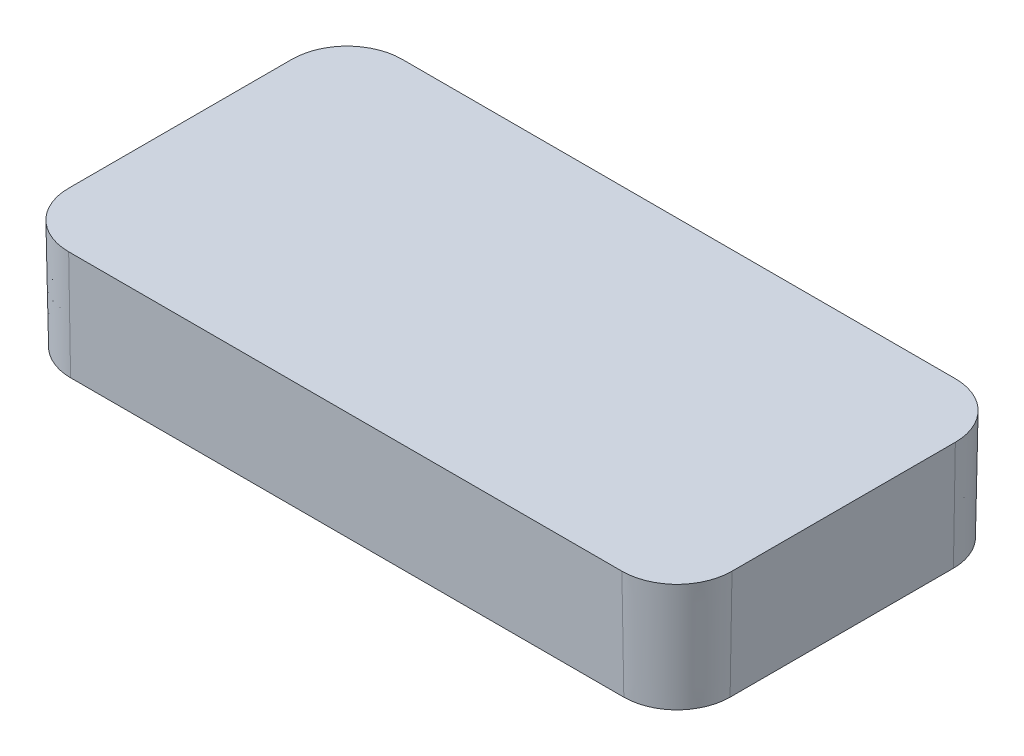
from build123d import *

# Parameters (mm, degrees)
BOSS_EXTRUDE1_DEPTH             = 2.3622
BOSS_EXTRUDE1_DRAFT             = -1
BOSS_EXTRUDE3_DEPTH             = 6.35
BOSS_EXTRUDE3_DRAFT             = -1
DRAFT1_ANGLE                    = 10
BOSS_EXTRUDE4_REACH             = 24.328
BOSS_EXTRUDE4_DIRECTION_2_REACH = 24.328
LPATTERN1_COUNT                 = 12
LPATTERN1_PITCH                 = 1.5875
LPATTERN1_COL_COUNT             = 12
LPATTERN1_COL_PITCH             = 1.5875
BOSS_EXTRUDE5_DEPTH             = 17.78
LPATTERN2_COUNT                 = 6
LPATTERN2_PITCH                 = 1.5875
LPATTERN2_COL_COUNT             = 6
LPATTERN2_COL_PITCH             = 1.5875
BOSS_EXTRUDE6_REACH             = 24.124
SKETCH10_R                      = 1.1811
SKETCH11_R                      = 1.1811
CUT_EXTRUDE1_DEPTH              = 23.123841069
MIRROR2_COPY_1_REACH            = 24.124
MIRROR2_COPY_1_SKETCH_R         = 1.1811
MIRROR2_COPY_2_SKETCH_R         = 1.1811
MIRROR2_COPY_2_DEPTH            = 23.123841069


with BuildPart() as part:
    # Sketch1 → Boss-Extrude1 (with draft: the straight prism first)
    with BuildSketch(Plane(origin=(0, 0, 0), x_dir=(1, 0, 0), z_dir=(0, 1, 0))):
        with BuildLine():
            Line((-15.9512, -9.6139), (15.9512, -9.6139))
            ThreePointArc((15.9512, -9.6139), (18.19626403, -8.68396403), (19.1262, -6.4389))
            Line((19.1262, -6.4389), (19.1262, 6.4389))
            ThreePointArc((19.1262, 6.4389), (18.19626403, 8.68396403), (15.9512, 9.6139))
            Line((15.9512, 9.6139), (-15.9512, 9.6139))
            ThreePointArc((-15.9512, 9.6139), (-18.19626403, 8.68396403), (-19.1262, 6.4389))
            Line((-19.1262, 6.4389), (-19.1262, -6.4389))
            ThreePointArc((-19.1262, -6.4389), (-18.19626403, -8.68396403), (-15.9512, -9.6139))
        make_face()
    extrude(amount=-BOSS_EXTRUDE1_DEPTH)
    # Boss-Extrude1: the draft: its side faces are tilted about the plane it starts from
    boss_extrude1_sides = [part.faces().sort_by_distance(p)[0] for p in [
        (0, -1.1811, 9.6139),
        (18.19626403, -1.1811, 8.68396403),
        (19.1262, -1.1811, 0),
        (18.19626403, -1.1811, -8.68396403),
        (0, -1.1811, -9.6139),
        (-18.19626403, -1.1811, -8.68396403),
        (-19.1262, -1.1811, 0),
        (-18.19626403, -1.1811, 8.68396403),
    ]]
    draft(boss_extrude1_sides, Plane(origin=(0, 0, 0), x_dir=(1, 0, 0), z_dir=(0, 1, 0)), BOSS_EXTRUDE1_DRAFT)


with BuildPart() as boss_extrude3_tool:
    # Sketch7 → Boss-Extrude3 (with draft: the straight prism first)
    with BuildSketch(Plane(origin=(0, 0, 0), x_dir=(1, 0, 0), z_dir=(0, 1, 0))):
        with BuildLine():
            Line((-15.9512, -9.6139), (15.9512, -9.6139))
            ThreePointArc((15.9512, -9.6139), (18.19626403, -8.68396403), (19.1262, -6.4389))
            Line((19.1262, -6.4389), (19.1262, 6.4389))
            ThreePointArc((19.1262, 6.4389), (18.19626403, 8.68396403), (15.9512, 9.6139))
            Line((15.9512, 9.6139), (-15.9512, 9.6139))
            ThreePointArc((-15.9512, 9.6139), (-18.19626403, 8.68396403), (-19.1262, 6.4389))
            Line((-19.1262, 6.4389), (-19.1262, -6.4389))
            ThreePointArc((-19.1262, -6.4389), (-18.19626403, -8.68396403), (-15.9512, -9.6139))
        make_face()
        with BuildLine():
            Line((-15.9512, -7.8359), (15.9512, -7.8359))
            ThreePointArc((15.9512, -7.8359), (16.939028173, -7.426728173), (17.3482, -6.4389))
            Line((17.3482, -6.4389), (17.3482, 6.4389))
            ThreePointArc((17.3482, 6.4389), (16.939028173, 7.426728173), (15.9512, 7.8359))
            Line((15.9512, 7.8359), (-15.9512, 7.8359))
            ThreePointArc((-15.9512, 7.8359), (-16.939028173, 7.426728173), (-17.3482, 6.4389))
            Line((-17.3482, 6.4389), (-17.3482, -6.4389))
            ThreePointArc((-17.3482, -6.4389), (-16.939028173, -7.426728173), (-15.9512, -7.8359))
        make_face(mode=Mode.SUBTRACT)
    extrude(amount=-BOSS_EXTRUDE3_DEPTH)
    # Boss-Extrude3: the draft: its side faces are tilted about the plane it starts from
    boss_extrude3_sides = [boss_extrude3_tool.faces().sort_by_distance(p)[0] for p in [
        (0, -3.175, 9.6139),
        (18.19626403, -3.175, 8.68396403),
        (19.1262, -3.175, 0),
        (18.19626403, -3.175, -8.68396403),
        (0, -3.175, -9.6139),
        (-18.19626403, -3.175, -8.68396403),
        (-19.1262, -3.175, 0),
        (-18.19626403, -3.175, 8.68396403),
        (-16.939028173, -3.175, 7.426728173),
        (-17.3482, -3.175, 0),
        (-16.939028173, -3.175, -7.426728173),
        (0, -3.175, -7.8359),
        (16.939028173, -3.175, -7.426728173),
        (17.3482, -3.175, 0),
        (16.939028173, -3.175, 7.426728173),
        (0, -3.175, 7.8359),
    ]]
    draft(boss_extrude3_sides, Plane(origin=(0, 0, 0), x_dir=(1, 0, 0), z_dir=(0, 1, 0)), BOSS_EXTRUDE3_DRAFT)


with BuildPart() as part_1:
    add(part.part)

    # Boss-Extrude3: add boss_extrude3_tool
    add(boss_extrude3_tool.part)

    # Draft1
    draft1_faces = [part_1.faces().sort_by_distance(p)[0] for p in [
        (-16.99279375, -4.3561, -7.48049375),
        (0, -4.3561, -7.911936008),
        (16.99279375, -4.3561, -7.48049375),
        (17.424236008, -4.3561, 0),
        (16.99279375, -4.3561, 7.48049375),
        (-16.99279375, -4.3561, 7.48049375),
        (0, -4.3561, 7.911936008),
        (-17.424236008, -4.3561, 0),
    ]]
    draft(draft1_faces, Plane(origin=(-15.9512, -2.3622, 6.4389), x_dir=(0, 0, -1), z_dir=(0, -1, 0)), DRAFT1_ANGLE)

    # Boss-Extrude4: up to this plane
    boss_extrude4_end = Plane(origin=(-15.9512, -2.3622, 7.877132354), z_dir=(0, -0.17364817766693072, -0.984807753012208))
    # Sketch8 → Boss-Extrude4 (add, up to the surface)
    with BuildSketch(Plane.XY, mode=Mode.PRIVATE) as boss_extrude4_sk1:
        Polygon((0, -3.15595), (0.79375, -2.3622), (-0.79375, -2.3622), align=None)
    boss_extrude4_tool1 = split(extrude(boss_extrude4_sk1.sketch, amount=BOSS_EXTRUDE4_REACH, mode=Mode.PRIVATE), bisect_by=boss_extrude4_end, keep=Keep.BOTH, mode=Mode.PRIVATE)
    boss_extrude4 = boss_extrude4_tool1.solids().sort_by_distance((0, -2.626783, 0))[0]
    add(boss_extrude4)

    # Boss-Extrude4 direction 2: up to this plane
    boss_extrude4_direction_2_end = Plane(origin=(-15.9512, -2.3622, -7.877132354), z_dir=(0, -0.17364817766693072, 0.984807753012208))
    # Sketch8 → Boss-Extrude4 direction 2 (add, up to the surface)
    with BuildSketch(Plane.XY, mode=Mode.PRIVATE) as boss_extrude4_direction_2_sk1:
        Polygon((0, -3.15595), (0.79375, -2.3622), (-0.79375, -2.3622), align=None)
    boss_extrude4_direction_2_tool1 = split(extrude(boss_extrude4_direction_2_sk1.sketch, amount=-BOSS_EXTRUDE4_DIRECTION_2_REACH, mode=Mode.PRIVATE), bisect_by=boss_extrude4_direction_2_end, keep=Keep.BOTH, mode=Mode.PRIVATE)
    boss_extrude4_direction_2 = boss_extrude4_direction_2_tool1.solids().sort_by_distance((0, -2.626783, 0))[0]
    add(boss_extrude4_direction_2)
    boss_extrude4 = boss_extrude4 + boss_extrude4_direction_2  # both directions under the feature's name, for the pattern or mirror that repeats it

    # LPattern1: Boss-Extrude4 ×12
    with Locations(*[(i * LPATTERN1_PITCH, 0, 0) for i in range(1, LPATTERN1_COUNT)]):
        add(boss_extrude4)

    # LPattern1 col: Boss-Extrude4 ×12
    with Locations(*[(-i * LPATTERN1_COL_PITCH, 0, 0) for i in range(1, LPATTERN1_COL_COUNT)]):
        add(boss_extrude4)

    # Sketch9 → Boss-Extrude5 (add, symmetric)
    with BuildSketch(Plane(origin=(0, 0, 0), x_dir=(0, 0, -1), z_dir=(1, 0, 0))):
        Polygon((0.79375, -2.3622), (-0.79375, -2.3622), (0, -3.15595), align=None)
    boss_extrude5 = extrude(amount=BOSS_EXTRUDE5_DEPTH, both=True)

    # LPattern2: Boss-Extrude5 ×6
    with Locations(*[(0, 0, i * LPATTERN2_PITCH) for i in range(1, LPATTERN2_COUNT)]):
        add(boss_extrude5)

    # LPattern2 col: Boss-Extrude5 ×6
    with Locations(*[(0, 0, -i * LPATTERN2_COL_PITCH) for i in range(1, LPATTERN2_COL_COUNT)]):
        add(boss_extrude5)

    # Sketch10 → Boss-Extrude6 (add, up to next)
    with BuildSketch(Plane(origin=(0, -5.588, 0), x_dir=(-1, 0, 0), z_dir=(0, -1, 0)), mode=Mode.PRIVATE) as boss_extrude6_sk1:
        with Locations((17.1061805, 7.5938805)):
            Circle(SKETCH10_R)
    boss_extrude6_tool1 = extrude(boss_extrude6_sk1.sketch, amount=-BOSS_EXTRUDE6_REACH, mode=Mode.PRIVATE) - part_1.part
    boss_extrude6 = boss_extrude6_tool1.solids().sort_by_distance((-17.106181, -5.588, -7.593881))[0]
    add(boss_extrude6)

    # Sketch11 → Cut-Extrude1 (cut, through all)
    with BuildSketch(Plane.XZ.offset(5.588)):
        with Locations((-17.1061805, -7.5938805)):
            Circle(SKETCH11_R)
    cut_extrude1 = extrude(amount=CUT_EXTRUDE1_DEPTH, mode=Mode.SUBTRACT)

    # Mirror1: Boss-Extrude6, Cut-Extrude1 across plane
    add(boss_extrude6.mirror(Plane(origin=(0, 0, 0), x_dir=(0, 0, 1), z_dir=(1, 0, 0))))
    add(cut_extrude1.mirror(Plane(origin=(0, 0, 0), x_dir=(0, 0, 1), z_dir=(1, 0, 0))), mode=Mode.SUBTRACT)

    # Mirror2: Boss-Extrude6, Cut-Extrude1 across plane
    add(boss_extrude6.mirror(Plane.XY))
    add(cut_extrude1.mirror(Plane.XY), mode=Mode.SUBTRACT)

    # Mirror2 copy 1 sketch → Mirror2 copy 1 (add, up to next)
    with BuildSketch(Plane.XZ.offset(5.588), mode=Mode.PRIVATE) as mirror2_copy_1_sk1:
        with Locations((17.1061805, 7.5938805)):
            Circle(MIRROR2_COPY_1_SKETCH_R)
    mirror2_copy_1_tool1 = extrude(mirror2_copy_1_sk1.sketch, amount=-MIRROR2_COPY_1_REACH, mode=Mode.PRIVATE) - part_1.part
    add(mirror2_copy_1_tool1.solids().sort_by_distance((17.106181, -5.588, 7.593881))[0])

    # Mirror2 copy 2 sketch → Mirror2 copy 2 (cut, through all)
    with BuildSketch(Plane(origin=(0, -5.588, 0), x_dir=(-1, 0, 0), z_dir=(0, -1, 0))):
        with Locations((-17.1061805, -7.5938805)):
            Circle(MIRROR2_COPY_2_SKETCH_R)
    extrude(amount=MIRROR2_COPY_2_DEPTH, mode=Mode.SUBTRACT)


solid = part_1.part
